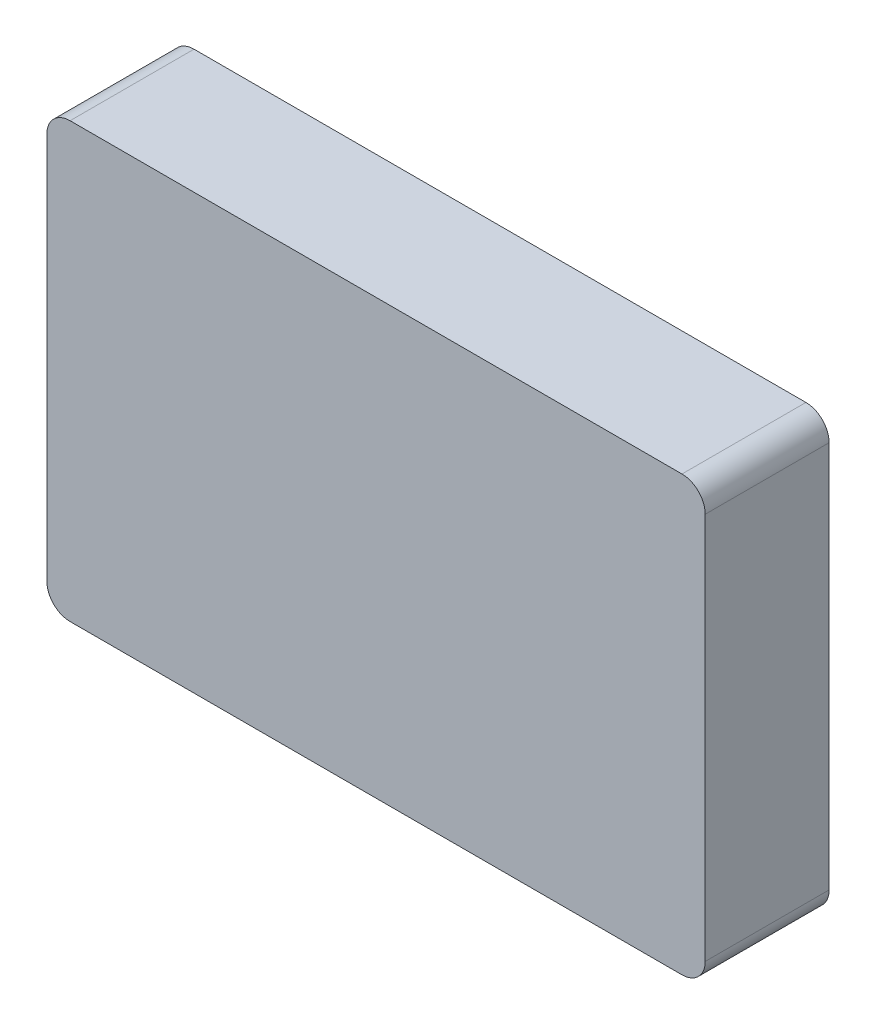
from build123d import *

# Parameters (mm, degrees)
BOSS_EXTRUDE1_DEPTH = 16


with BuildPart() as part:
    # Sketch1 → Boss-Extrude1 (new body)
    with BuildSketch(Plane.XY):
        with BuildLine():
            Line((-39.5, 28), (39.5, 28))
            ThreePointArc((39.5, 28), (41.621320344, 27.121320344), (42.5, 25))
            Line((42.5, 25), (42.5, -25))
            ThreePointArc((42.5, -25), (41.621320344, -27.121320344), (39.5, -28))
            Line((39.5, -28), (-39.5, -28))
            ThreePointArc((-39.5, -28), (-41.621320344, -27.121320344), (-42.5, -25))
            Line((-42.5, -25), (-42.5, 25))
            ThreePointArc((-42.5, 25), (-41.621320344, 27.121320344), (-39.5, 28))
        make_face()
    extrude(amount=BOSS_EXTRUDE1_DEPTH)


solid = part.part
